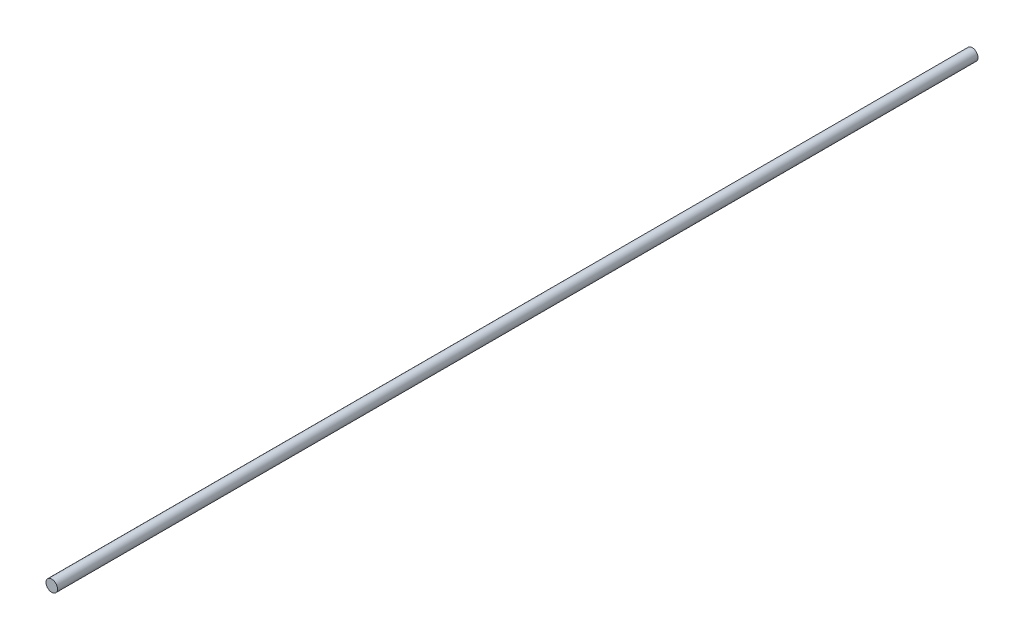
from build123d import *

# Parameters (mm, degrees)
SKETCH1_R           = 3.175
BOSS_EXTRUDE1_DEPTH = 508


with BuildPart() as part:
    # Sketch1 → Boss-Extrude1 (new body)
    with BuildSketch(Plane.XY):
        Circle(SKETCH1_R)
    extrude(amount=BOSS_EXTRUDE1_DEPTH)


solid = part.part
